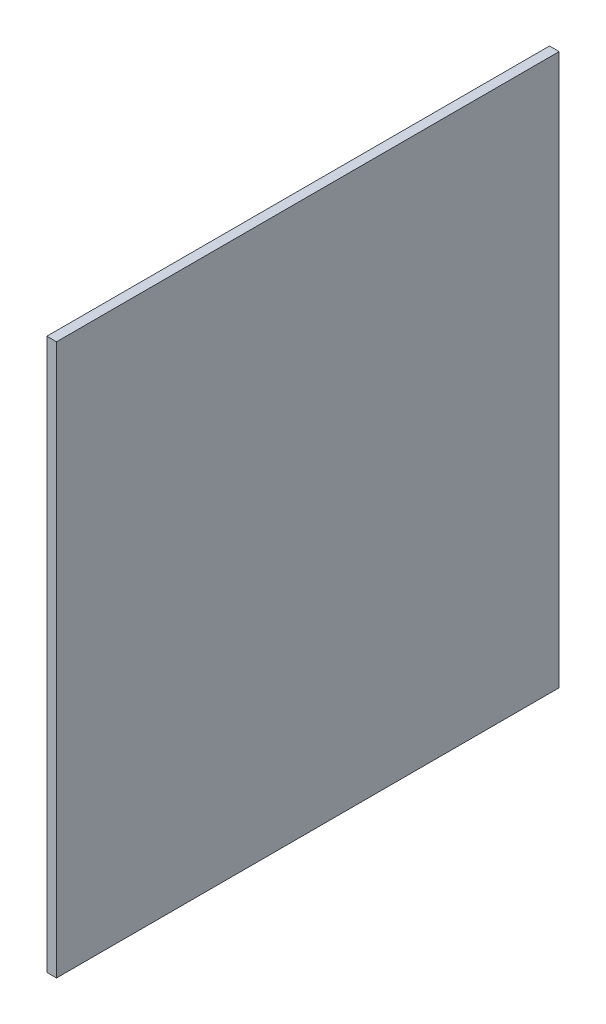
from build123d import *

# Parameters (mm, degrees)
ESQUISSE1_W        = 520
ESQUISSE1_H        = 570
BOSS_EXTRU_1_DEPTH = 10


with BuildPart() as part:
    # Esquisse1 → Boss.-Extru.1 (new body)
    with BuildSketch(Plane(origin=(0, 0, 0), x_dir=(0, 0, -1), z_dir=(1, 0, 0))):
        with Locations((-146.87732342, -52.871747212)):
            Rectangle(ESQUISSE1_W, ESQUISSE1_H)
    extrude(amount=BOSS_EXTRU_1_DEPTH)


solid = part.part
